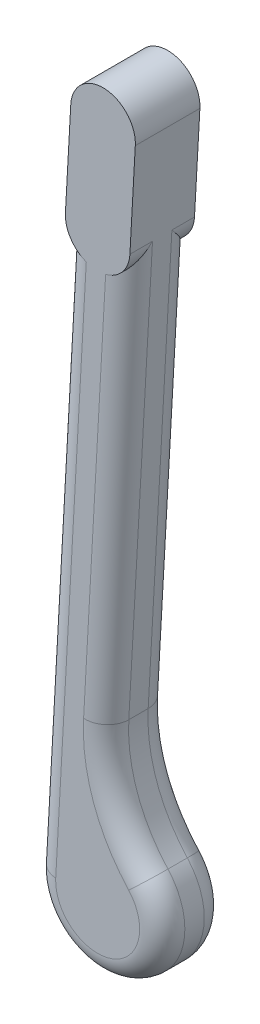
from build123d import *

# Parameters (mm, degrees)
EXTRUDE_1_DEPTH = 20
FILLET_1_R      = 7
EXTRUDE_2_DEPTH = 20


with BuildPart() as part:
    # 草图1 → 凸台-拉伸1 (new body)
    with BuildSketch(Plane.XY):
        with BuildLine():
            Line((-9.984555975, 0.555555556), (-19.969111951, -178.888888889))
            ThreePointArc((-19.969111951, -178.888888889), (6.717955109, -198.837969083), (14.759919727, -166.503897983))
            ThreePointArc((14.759919727, -166.503897983), (5.273090806, -150.735790608), (2.641695759, -132.52291348))
            Line((2.641695759, -132.52291348), (9.984555975, -0.555555556))
            ThreePointArc((9.984555975, -0.555555556), (0.555555556, 9.984555975), (-9.984555975, 0.555555556))
        make_face()
    extrude(amount=EXTRUDE_1_DEPTH)

    # 圆角1
    fillet_1_edges = [part.edges().sort_by_distance(p)[0] for p in [
        (6.313125867, -66.539234518, 20),
        (0.555555556, 9.984555975, 20),
        (-14.976833963, -89.166666667, 20),
        (6.717955109, -198.837969083, 20),
        (-14.976833963, -89.166666667, 0),
        (0.555555556, 9.984555975, 0),
        (6.313125867, -66.539234518, 0),
        (5.273090806, -150.735790608, 0),
        (6.717955109, -198.837969083, 0),
        (5.273090806, -150.735790608, 20),
    ]]
    fillet(fillet_1_edges, radius=FILLET_1_R)

    # 草图2 → 凸台-拉伸2 (add)
    with BuildSketch(Plane.XY):
        with BuildLine():
            Line((-9.984555975, 0.555555556), (-8.317889309, 30.509223482))
            ThreePointArc((-8.317889309, 30.509223482), (2.222222222, 39.938223901), (11.651222642, 29.39811237))
            Line((11.651222642, 29.39811237), (9.984555975, -0.555555556))
            ThreePointArc((9.984555975, -0.555555556), (-0.555555556, -9.984555975), (-9.984555975, 0.555555556))
        make_face()
    extrude(amount=EXTRUDE_2_DEPTH)


solid = part.part
